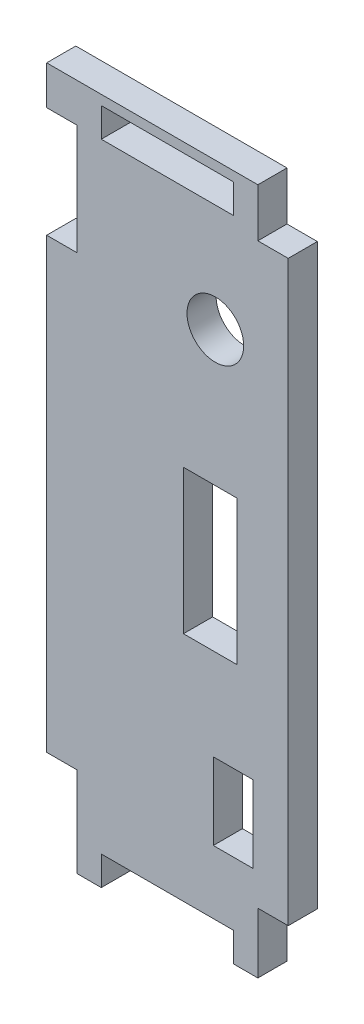
from build123d import *

# Parameters (mm, degrees)
SKETCH1_W           = 4.1783
SKETCH1_H           = 8.0391
SKETCH1_W_2         = 5.588
SKETCH1_H_2         = 15.0876
SKETCH1_W_3         = 13.843
SKETCH1_H_3         = 3.048
SKETCH1_R           = 2.96545
BOSS_EXTRUDE1_DEPTH = 3.048


with BuildPart() as part:
    # Sketch1 → Boss-Extrude1 (new body)
    with BuildSketch(Plane.XY):
        Polygon((3.175, 64.77), (3.175, 53.213), (0, 53.213), (0, 6.35), (3.175, 6.35), (3.175, -3.048), (5.715, -3.048), (5.715, 0), (19.558, 0), (19.558, -3.048), (22.098, -3.048), (22.098, 3.2766), (25.273, 3.2766), (25.273, 63.754), (22.098, 63.754), (22.098, 68.834), (0, 68.834), (0, 64.77), align=None)
        with Locations((19.52625, 10.64895)):
            Rectangle(SKETCH1_W, SKETCH1_H, mode=Mode.SUBTRACT)
        with Locations((17.1069, 31.8008)):
            Rectangle(SKETCH1_W_2, SKETCH1_H_2, mode=Mode.SUBTRACT)
        with Locations((12.6365, 66.294)):
            Rectangle(SKETCH1_W_3, SKETCH1_H_3, mode=Mode.SUBTRACT)
        with Locations((17.64665, 53.48605)):
            Circle(SKETCH1_R, mode=Mode.SUBTRACT)
    extrude(amount=BOSS_EXTRUDE1_DEPTH)


solid = part.part
